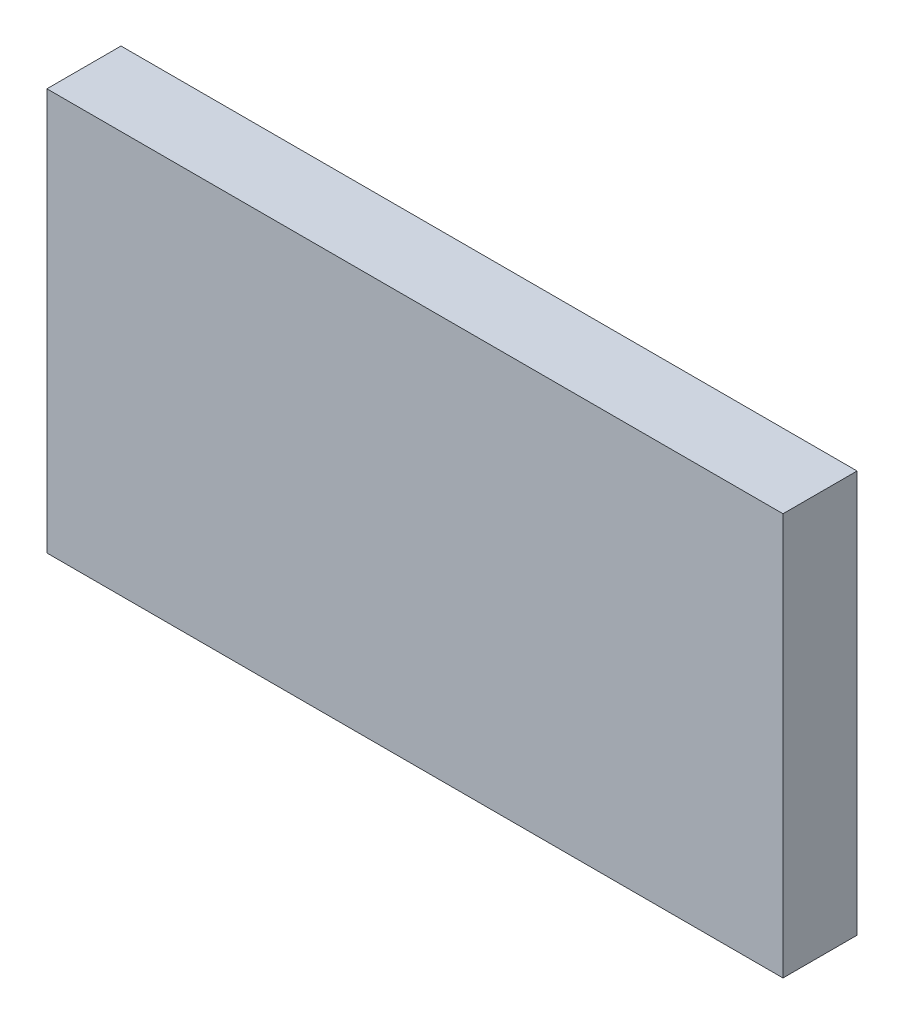
from build123d import *

# Parameters (mm, degrees)
SKETCH1_W                = 150
SKETCH1_H                = 80
BOSS_EXTRUDE1_DEPTH      = 10
FILLET1_R                = 3
F_5_0_5_DIAMETER_HOLE1_D = 5
CUT_EXTRUDE1_DEPTH       = 8
FILLET2_R                = 3.5
SKETCH8_W                = 153.924
SKETCH8_H                = 84.074
BOSS_EXTRUDE3_DEPTH      = 0.508
BOSS_EXTRUDE3_DEPTH_BACK = 14.986


with BuildPart() as part:
    # Sketch1 → Boss-Extrude1 (new body)
    with BuildSketch(Plane.XY):
        Rectangle(SKETCH1_W, SKETCH1_H)
    extrude(amount=BOSS_EXTRUDE1_DEPTH)

    # Fillet1
    fillet1_edges = [part.edges().sort_by_distance(p)[0] for p in [
        (75, -40, 5),
        (-75, -40, 5),
        (-75, 40, 5),
        (75, 40, 5),
    ]]
    fillet(fillet1_edges, radius=FILLET1_R)

    # Ø5.0 (5) Diameter Hole1 (through all)
    with Locations(Plane.XY.offset(10)):
        with Locations((-70, -35), (-70, 35), (70, 35), (70, -35)):
            Hole(F_5_0_5_DIAMETER_HOLE1_D / 2)

    # Sketch5 → Cut-Extrude1 (cut)
    with BuildSketch(Plane.XY.offset(10)):
        with BuildLine():
            Line((-59.04554885, 34), (59.04554885, 34))
            ThreePointArc((59.04554885, 34), (62.221825407, 27.221825407), (69, 24.04554885))
            Line((69, 24.04554885), (69, -24.04554885))
            ThreePointArc((69, -24.04554885), (62.221825407, -27.221825407), (59.04554885, -34))
            Line((59.04554885, -34), (-59.04554885, -34))
            ThreePointArc((-59.04554885, -34), (-62.221825407, -27.221825407), (-69, -24.04554885))
            Line((-69, -24.04554885), (-69, 24.04554885))
            ThreePointArc((-69, 24.04554885), (-62.221825407, 27.221825407), (-59.04554885, 34))
        make_face()
    extrude(amount=-CUT_EXTRUDE1_DEPTH, mode=Mode.SUBTRACT)

    # Fillet2
    fillet2_edges = [part.edges().sort_by_distance(p)[0] for p in [
        (-69, 24.04554885, 6),
        (-59.04554885, 34, 6),
        (59.04554885, 34, 6),
        (69, 24.04554885, 6),
        (69, -24.04554885, 6),
        (59.04554885, -34, 6),
        (-59.04554885, -34, 6),
        (-69, -24.04554885, 6),
    ]]
    fillet(fillet2_edges, radius=FILLET2_R)


with BuildPart() as body_2:
    # Sketch8 → Boss-Extrude3 (new body, two sides)
    with BuildSketch(Plane.XY.offset(10)) as boss_extrude3_sk:
        Rectangle(SKETCH8_W, SKETCH8_H)
    extrude(amount=BOSS_EXTRUDE3_DEPTH)
    extrude(boss_extrude3_sk.sketch, amount=-BOSS_EXTRUDE3_DEPTH_BACK)


solid = Compound([part.part, body_2.part])
